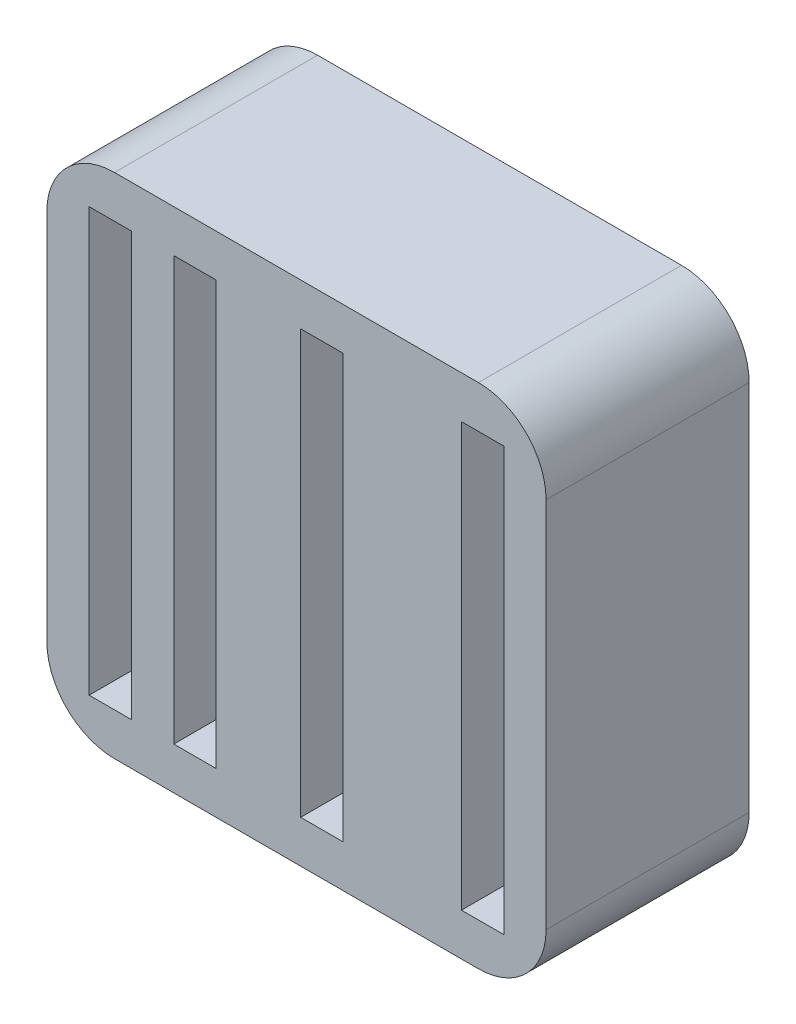
from build123d import *

# Parameters (mm, degrees)
SKETCH1_W           = 29.5
SKETCH1_H           = 30
BOSS_EXTRUDE3_DEPTH = 2
SKETCH1_8_W         = 29.5
SKETCH1_8_H         = 30
SKETCH1_8_W_2       = 2.5
SKETCH1_8_H_2       = 25
BOSS_EXTRUDE4_DEPTH = 12
FILLET2_R           = 4


with BuildPart() as part:
    # Sketch1 → Boss-Extrude3 (new body)
    with BuildSketch(Plane.XY):
        with Locations((4.277950311, -6.798136646)):
            Rectangle(SKETCH1_W, SKETCH1_H)
    extrude(amount=BOSS_EXTRUDE3_DEPTH)

    # Sketch1_8 → Boss-Extrude4 (add)
    with BuildSketch(Plane.XY):
        with Locations((4.277950311, -6.798136646)):
            Rectangle(SKETCH1_8_W, SKETCH1_8_H)
        with Locations((15.277950311, -6.798136646)):
            Rectangle(SKETCH1_8_W_2, SKETCH1_8_H_2, mode=Mode.SUBTRACT)
        with Locations((5.777950311, -6.798136646)):
            Rectangle(SKETCH1_8_W_2, SKETCH1_8_H_2, mode=Mode.SUBTRACT)
        with Locations((-1.722049689, -6.798136646)):
            Rectangle(SKETCH1_8_W_2, SKETCH1_8_H_2, mode=Mode.SUBTRACT)
        with Locations((-6.722049689, -6.798136646)):
            Rectangle(SKETCH1_8_W_2, SKETCH1_8_H_2, mode=Mode.SUBTRACT)
    extrude(amount=BOSS_EXTRUDE4_DEPTH)

    # Fillet2
    fillet2_edges = [part.edges().sort_by_distance(p)[0] for p in [
        (19.027950311, -21.798136646, 6),
        (-10.472049689, -21.798136646, 6),
        (-10.472049689, 8.201863354, 6),
        (19.027950311, 8.201863354, 6),
    ]]
    fillet(fillet2_edges, radius=FILLET2_R)


solid = part.part
